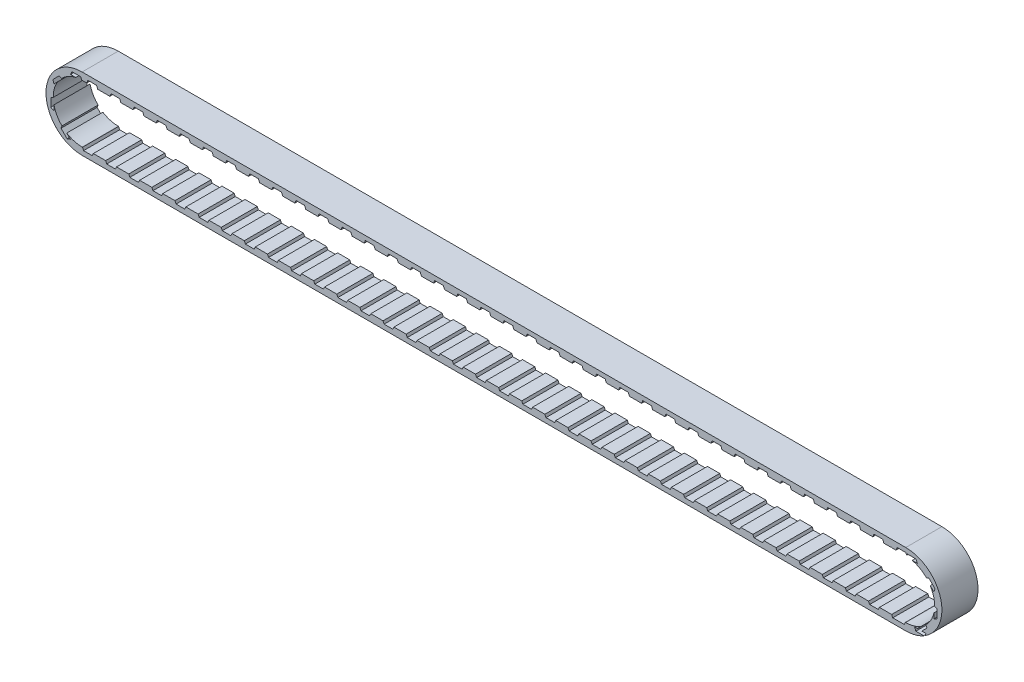
from build123d import *

# Parameters (mm, degrees)
BOSS_EXTRUDE1_DEPTH  = 6.35
CUT_EXTRUDE1_DEPTH   = 8.89
LPATTERN3_COUNT      = 42
LPATTERN3_PITCH      = 4.064
CIRPATTERN1_COUNT    = 8
MIRROR1_COPY_1_DEPTH = 8.89
MIRROR1_COPY_2_DEPTH = 8.89
MIRROR1_COPY_3_DEPTH = 8.89
MIRROR1_COPY_4_DEPTH = 8.89
MIRROR1_COPY_5_DEPTH = 8.89
MIRROR1_COPY_6_DEPTH = 8.89
MIRROR1_COPY_7_DEPTH = 8.89
CUT_EXTRUDE2_DEPTH   = 8.89
LPATTERN2_COUNT      = 36
LPATTERN2_PITCH      = 4.064


with BuildPart() as part:
    # Sketch1 → Boss-Extrude1 (new body)
    with BuildSketch(Plane.XY):
        with BuildLine():
            Line((-72.39, 6.35), (72.39, 6.35))
            ThreePointArc((72.39, 6.35), (78.74, 0), (72.39, -6.35))
            Line((72.39, -6.35), (-72.39, -6.35))
            ThreePointArc((-72.39, -6.35), (-78.74, 0), (-72.39, 6.35))
        make_face()
        with BuildLine():
            Line((-72.39, 5.08), (72.39, 5.08))
            ThreePointArc((72.39, 5.08), (77.47, 0), (72.39, -5.08))
            Line((72.39, -5.08), (-72.39, -5.08))
            ThreePointArc((-72.39, -5.08), (-77.47, 0), (-72.39, 5.08))
        make_face(mode=Mode.SUBTRACT)
    extrude(amount=-BOSS_EXTRUDE1_DEPTH)

    # Sketch2 → Cut-Extrude1 (cut)
    with BuildSketch(Plane.XY):
        Polygon((-72.39, -4.953), (-70.358, -4.953), (-70.612, -5.500699929), (-72.136, -5.500699929), align=None)
    cut_extrude1 = extrude(amount=-CUT_EXTRUDE1_DEPTH, mode=Mode.SUBTRACT)

    # LPattern3: Cut-Extrude1 ×42
    with Locations(*[(i * LPATTERN3_PITCH, 0, 0) for i in range(1, LPATTERN3_COUNT)]):
        add(cut_extrude1, mode=Mode.SUBTRACT)

    # CirPattern1: Cut-Extrude1 ×8 about axis
    cirpattern1_axis = Axis((-72.39, 0, 0), (0, 0, 1))
    for i in range(1, CIRPATTERN1_COUNT):
        add(cut_extrude1.rotate(cirpattern1_axis, i * 360 / CIRPATTERN1_COUNT), mode=Mode.SUBTRACT)

    # Mirror1: Cut-Extrude1 across plane
    add(cut_extrude1.mirror(Plane(origin=(0, 0, 0), x_dir=(0, 0, 1), z_dir=(1, 0, 0))), mode=Mode.SUBTRACT)

    # Mirror1 copy 1 sketch → Mirror1 copy 1 (cut)
    with BuildSketch(Plane(origin=(21.20254011, 51.18745989, 0), x_dir=(-0.707106781, 0.707106781, 0), z_dir=(0, 0, 1))):
        Polygon((-72.39, 4.953), (-70.358, 4.953), (-70.612, 5.500699929), (-72.136, 5.500699929), align=None)
    extrude(amount=-MIRROR1_COPY_1_DEPTH, mode=Mode.SUBTRACT)

    # Mirror1 copy 2 sketch → Mirror1 copy 2 (cut)
    with BuildSketch(Plane(origin=(72.39, 72.39, 0), x_dir=(0, 1, 0), z_dir=(0, 0, 1))):
        Polygon((-72.39, 4.953), (-70.358, 4.953), (-70.612, 5.500699929), (-72.136, 5.500699929), align=None)
    extrude(amount=-MIRROR1_COPY_2_DEPTH, mode=Mode.SUBTRACT)

    # Mirror1 copy 3 sketch → Mirror1 copy 3 (cut)
    with BuildSketch(Plane(origin=(123.57745989, 51.18745989, 0), x_dir=(0.707106781, 0.707106781, 0), z_dir=(0, 0, 1))):
        Polygon((-72.39, 4.953), (-70.358, 4.953), (-70.612, 5.500699929), (-72.136, 5.500699929), align=None)
    extrude(amount=-MIRROR1_COPY_3_DEPTH, mode=Mode.SUBTRACT)

    # Mirror1 copy 4 sketch → Mirror1 copy 4 (cut)
    with BuildSketch(Plane(origin=(144.78, 0, 0), x_dir=(1, 0, 0), z_dir=(0, 0, 1))):
        Polygon((-72.39, 4.953), (-70.358, 4.953), (-70.612, 5.500699929), (-72.136, 5.500699929), align=None)
    extrude(amount=-MIRROR1_COPY_4_DEPTH, mode=Mode.SUBTRACT)

    # Mirror1 copy 5 sketch → Mirror1 copy 5 (cut)
    with BuildSketch(Plane(origin=(123.57745989, -51.18745989, 0), x_dir=(0.707106781, -0.707106781, 0), z_dir=(0, 0, 1))):
        Polygon((-72.39, 4.953), (-70.358, 4.953), (-70.612, 5.500699929), (-72.136, 5.500699929), align=None)
    extrude(amount=-MIRROR1_COPY_5_DEPTH, mode=Mode.SUBTRACT)

    # Mirror1 copy 6 sketch → Mirror1 copy 6 (cut)
    with BuildSketch(Plane(origin=(72.39, -72.39, 0), x_dir=(0, -1, 0), z_dir=(0, 0, 1))):
        Polygon((-72.39, 4.953), (-70.358, 4.953), (-70.612, 5.500699929), (-72.136, 5.500699929), align=None)
    extrude(amount=-MIRROR1_COPY_6_DEPTH, mode=Mode.SUBTRACT)

    # Mirror1 copy 7 sketch → Mirror1 copy 7 (cut)
    with BuildSketch(Plane(origin=(21.20254011, -51.18745989, 0), x_dir=(-0.707106781, -0.707106781, 0), z_dir=(0, 0, 1))):
        Polygon((-72.39, 4.953), (-70.358, 4.953), (-70.612, 5.500699929), (-72.136, 5.500699929), align=None)
    extrude(amount=-MIRROR1_COPY_7_DEPTH, mode=Mode.SUBTRACT)

    # Sketch3 → Cut-Extrude2 (cut)
    with BuildSketch(Plane.XY):
        Polygon((-71.628, 4.953), (-69.596, 4.953), (-69.85, 5.588), (-71.374, 5.588), align=None)
    cut_extrude2 = extrude(amount=-CUT_EXTRUDE2_DEPTH, mode=Mode.SUBTRACT)

    # LPattern2: Cut-Extrude2 ×36
    with Locations(*[(i * LPATTERN2_PITCH, 0, 0) for i in range(1, LPATTERN2_COUNT)]):
        add(cut_extrude2, mode=Mode.SUBTRACT)


solid = part.part
